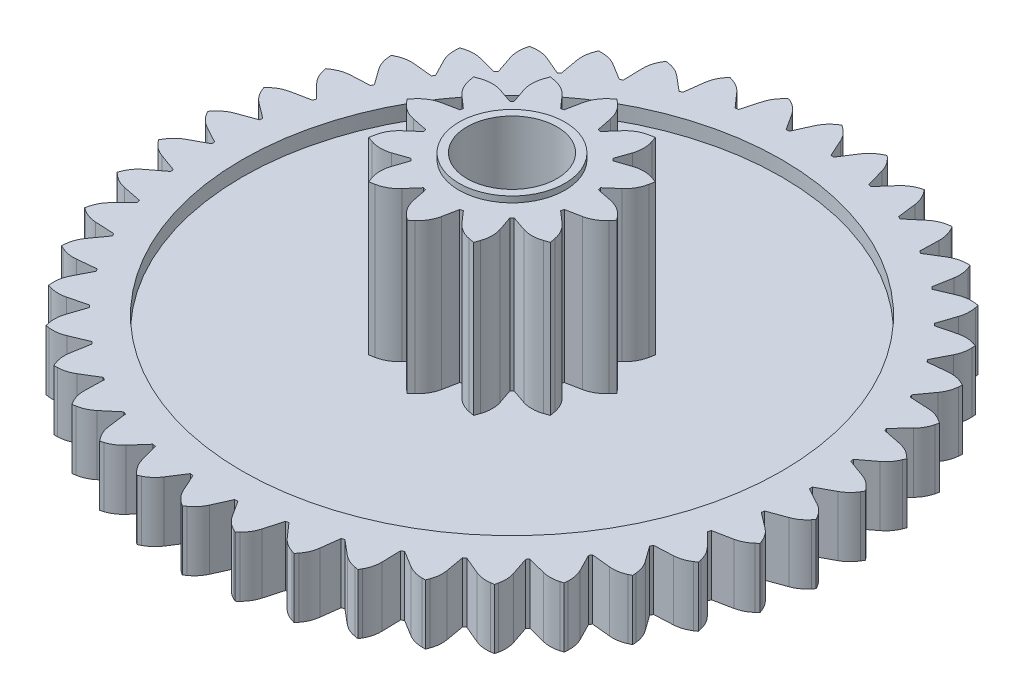
from build123d import *

# Parameters (mm, degrees)
SKETCH1_R           = 11
BOSS_EXTRUDE1_DEPTH = 2
SKETCH2_OUTSIDE_W   = 30.236
SKETCH2_OUTSIDE_H   = 30.236
CUT_EXTRUDE1_DEPTH  = 2
SKETCH3_R           = 9
CUT_EXTRUDE2_DEPTH  = 0.5
SKETCH4_R           = 9
SKETCH4_R_2         = 6.5
SKETCH4_R_3         = 6
CUT_EXTRUDE3_DEPTH  = 0.5
FILLET1_R           = 0.2
BOSS_EXTRUDE2_DEPTH = 5
SKETCH6_R           = 1.5
CUT_EXTRUDE4_DEPTH  = 7.5
SKETCH7_R           = 1.769136677
SKETCH7_R_2         = 1.5
BOSS_EXTRUDE3_DEPTH = 0.2


with BuildPart() as part:
    # Sketch1 → Boss-Extrude1 (new body)
    with BuildSketch(Plane(origin=(0, 0, 0), x_dir=(1, 0, 0), z_dir=(0, 1, 0))):
        Circle(SKETCH1_R)
    extrude(amount=BOSS_EXTRUDE1_DEPTH)

    # Sketch2 outside → Cut-Extrude1 (cut)
    with BuildSketch(Plane(origin=(0, 2, 0), x_dir=(1, 0, 0), z_dir=(0, 1, 0))):
        Rectangle(SKETCH2_OUTSIDE_W, SKETCH2_OUTSIDE_H)
        with BuildLine():
            Line((0.79486256, 9.937629242), (0.695142181, 9.945102252))
            Line((0.695142181, 9.945102252), (0.434286573, 10.524405322))
            ThreePointArc((0.434286573, 10.524405322), (0.292252152, 10.752119541), (0.094771839, 10.933858552))
            Line((0.094771839, 10.933858552), (0, 11))
            Line((0, 11), (-0.094771839, 10.933858552))
            ThreePointArc((-0.094771839, 10.933858552), (-0.292252152, 10.752119541), (-0.434286573, 10.524405322))
            Line((-0.434286573, 10.524405322), (-0.695142181, 9.945102252))
            Line((-0.695142181, 9.945102252), (-0.79486256, 9.937629242))
            Line((-0.79486256, 9.937629242), (-1.139145269, 10.471583465))
            ThreePointArc((-1.139145269, 10.471583465), (-1.313532325, 10.675585173), (-1.535893741, 10.825861396))
            Line((-1.535893741, 10.825861396), (-1.639464928, 10.877139088))
            Line((-1.639464928, 10.877139088), (-1.723320373, 10.797611376))
            ThreePointArc((-1.723320373, 10.797611376), (-1.8915082, 10.588469327), (-1.99801717, 10.342129355))
            Line((-1.99801717, 10.342129355), (-2.169618594, 9.730418111))
            Line((-2.169618594, 9.730418111), (-2.267111385, 9.708166017))
            Line((-2.267111385, 9.708166017), (-2.687130487, 10.184843737))
            ThreePointArc((-2.687130487, 10.184843737), (-2.889974661, 10.360575872), (-3.132249992, 10.476032385))
            Line((-3.132249992, 10.476032385), (-3.242306919, 10.511300864))
            Line((-3.242306919, 10.511300864), (-3.313372777, 10.420163405))
            ThreePointArc((-3.313372777, 10.420163405), (-3.44851108, 10.188290204), (-3.517115365, 9.928827308))
            Line((-3.517115365, 9.928827308), (-3.595629313, 9.298372508))
            Line((-3.595629313, 9.298372508), (-3.688716687, 9.261838405))
            Line((-3.688716687, 9.261838405), (-4.175089651, 9.67059143))
            ThreePointArc((-4.175089651, 9.67059143), (-4.401859739, 9.814128427), (-4.658636955, 9.892186122))
            Line((-4.658636955, 9.892186122), (-4.77272113, 9.910657547))
            Line((-4.77272113, 9.910657547), (-4.829409908, 9.809946202))
            ThreePointArc((-4.829409908, 9.809946202), (-4.928479921, 9.560521514), (-4.957647015, 9.293731666))
            Line((-4.957647015, 9.293731666), (-4.941319614, 8.658616628))
            Line((-4.941319614, 8.658616628), (-5.027922155, 8.608616628))
            Line((-5.027922155, 8.608616628), (-5.569784211, 8.940314091))
            ThreePointArc((-5.569784211, 8.940314091), (-5.815414544, 9.048449571), (-6.080957666, 9.087364767))
            Line((-6.080957666, 9.087364767), (-6.196520639, 9.088626517))
            Line((-6.196520639, 9.088626517), (-6.237566003, 8.980591011))
            ThreePointArc((-6.237566003, 8.980591011), (-6.298354665, 8.719186572), (-6.287433023, 8.451029416))
            Line((-6.287433023, 8.451029416), (-6.176629001, 7.825441561))
            Line((-6.176629001, 7.825441561), (-6.254812149, 7.763092581))
            Line((-6.254812149, 7.763092581), (-6.840058996, 8.010324908))
            ThreePointArc((-6.840058996, 8.010324908), (-7.099062598, 8.080643303), (-7.367439832, 8.079546699))
            Line((-7.367439832, 8.079546699), (-7.481900115, 8.06357059))
            Line((-7.481900115, 8.06357059), (-7.50638518, 7.950624257))
            ThreePointArc((-7.50638518, 7.950624257), (-7.527534573, 7.683079409), (-7.476768166, 7.419545134))
            Line((-7.476768166, 7.419545134), (-7.273962703, 6.817459061))
            Line((-7.273962703, 6.817459061), (-7.341979976, 6.744153874))
            Line((-7.341979976, 6.744153874), (-7.957538166, 6.901398304))
            ThreePointArc((-7.957538166, 6.901398304), (-8.224129324, 6.932328816), (-8.489345566, 6.89124491))
            Line((-8.489345566, 6.89124491), (-8.600146307, 6.85838782))
            Line((-8.600146307, 6.85838782), (-8.607524116, 6.743053695))
            ThreePointArc((-8.607524116, 6.743053695), (-8.588561797, 6.475344949), (-8.499084664, 6.222320474))
            Line((-8.499084664, 6.222320474), (-8.208808097, 5.657185791))
            Line((-8.208808097, 5.657185791), (-8.265140103, 5.574561913))
            Line((-8.265140103, 5.574561913), (-8.897259082, 5.638305865))
            ThreePointArc((-8.897259082, 5.638305865), (-9.165482591, 5.629157559), (-9.421613348, 5.549004096))
            Line((-9.421613348, 5.549004096), (-9.526279442, 5.5))
            Line((-9.526279442, 5.5), (-9.516385187, 5.384854456))
            ThreePointArc((-9.516385187, 5.384854456), (-9.457734743, 5.122961982), (-9.331545655, 4.886099456))
            Line((-9.331545655, 4.886099456), (-8.960282283, 4.370540338))
            Line((-8.960282283, 4.370540338), (-9.003670657, 4.280443452))
            Line((-9.003670657, 4.280443452), (-9.638229933, 4.249262991))
            ThreePointArc((-9.638229933, 4.249262991), (-9.902094122, 4.200240224), (-10.143417857, 4.082807701))
            Line((-10.143417857, 4.082807701), (-10.239611235, 4.018751268))
            Line((-10.239611235, 4.018751268), (-10.212665938, 3.906366467))
            ThreePointArc((-10.212665938, 3.906366467), (-10.115637524, 3.656140511), (-9.955555336, 3.440731051))
            Line((-9.955555336, 3.440731051), (-9.51159857, 2.986264237))
            Line((-9.51159857, 2.986264237), (-9.541074087, 2.890706956))
            Line((-9.541074087, 2.890706956), (-10.163898654, 2.765298603))
            ThreePointArc((-10.163898654, 2.765298603), (-10.417509234, 2.677496463), (-10.638635172, 2.525408128))
            Line((-10.638635172, 2.525408128), (-10.724207034, 2.447730274))
            Line((-10.724207034, 2.447730274), (-10.680812609, 2.340616705))
            ThreePointArc((-10.680812609, 2.340616705), (-10.547573678, 2.107646901), (-10.357174361, 1.9185024))
            Line((-10.357174361, 1.9185024), (-9.850441462, 1.535279927))
            Line((-9.850441462, 1.535279927), (-9.865345689, 1.436396844))
            Line((-9.865345689, 1.436396844), (-10.462522674, 1.219562014))
            ThreePointArc((-10.462522674, 1.219562014), (-10.700214404, 1.094941856), (-10.896202958, 0.911595111))
            Line((-10.896202958, 0.911595111), (-10.969241769, 0.822031029))
            Line((-10.969241769, 0.822031029), (-10.910367575, 0.722581435))
            ThreePointArc((-10.910367575, 0.722581435), (-10.743894465, 0.512071943), (-10.527431226, 0.353417575))
            Line((-10.527431226, 0.353417575), (-9.969241769, 0.05))
            Line((-9.969241769, 0.05), (-9.969241769, -0.05))
            Line((-9.969241769, -0.05), (-10.527431226, -0.353417575))
            ThreePointArc((-10.527431226, -0.353417575), (-10.743894465, -0.512071943), (-10.910367575, -0.722581435))
            Line((-10.910367575, -0.722581435), (-10.969241769, -0.822031029))
            Line((-10.969241769, -0.822031029), (-10.896202958, -0.911595111))
            ThreePointArc((-10.896202958, -0.911595111), (-10.700214404, -1.094941856), (-10.462522674, -1.219562014))
            Line((-10.462522674, -1.219562014), (-9.865345689, -1.436396844))
            Line((-9.865345689, -1.436396844), (-9.850441462, -1.535279927))
            Line((-9.850441462, -1.535279927), (-10.357174361, -1.9185024))
            ThreePointArc((-10.357174361, -1.9185024), (-10.547573678, -2.107646901), (-10.680812609, -2.340616705))
            Line((-10.680812609, -2.340616705), (-10.724207034, -2.447730274))
            Line((-10.724207034, -2.447730274), (-10.638635172, -2.525408128))
            ThreePointArc((-10.638635172, -2.525408128), (-10.417509234, -2.677496463), (-10.163898654, -2.765298603))
            Line((-10.163898654, -2.765298603), (-9.541074087, -2.890706956))
            Line((-9.541074087, -2.890706956), (-9.51159857, -2.986264237))
            Line((-9.51159857, -2.986264237), (-9.955555336, -3.440731051))
            ThreePointArc((-9.955555336, -3.440731051), (-10.115637524, -3.656140511), (-10.212665938, -3.906366467))
            Line((-10.212665938, -3.906366467), (-10.239611235, -4.018751268))
            Line((-10.239611235, -4.018751268), (-10.143417857, -4.082807701))
            ThreePointArc((-10.143417857, -4.082807701), (-9.902094122, -4.200240224), (-9.638229933, -4.249262991))
            Line((-9.638229933, -4.249262991), (-9.003670657, -4.280443452))
            Line((-9.003670657, -4.280443452), (-8.960282283, -4.370540338))
            Line((-8.960282283, -4.370540338), (-9.331545655, -4.886099456))
            ThreePointArc((-9.331545655, -4.886099456), (-9.457734743, -5.122961982), (-9.516385187, -5.384854456))
            Line((-9.516385187, -5.384854456), (-9.526279442, -5.5))
            Line((-9.526279442, -5.5), (-9.421613348, -5.549004096))
            ThreePointArc((-9.421613348, -5.549004096), (-9.165482591, -5.629157559), (-8.897259082, -5.638305865))
            Line((-8.897259082, -5.638305865), (-8.265140103, -5.574561913))
            Line((-8.265140103, -5.574561913), (-8.208808097, -5.657185791))
            Line((-8.208808097, -5.657185791), (-8.499084664, -6.222320474))
            ThreePointArc((-8.499084664, -6.222320474), (-8.588561797, -6.475344949), (-8.607524116, -6.743053695))
            Line((-8.607524116, -6.743053695), (-8.600146307, -6.85838782))
            Line((-8.600146307, -6.85838782), (-8.489345566, -6.89124491))
            ThreePointArc((-8.489345566, -6.89124491), (-8.224129324, -6.932328816), (-7.957538166, -6.901398304))
            Line((-7.957538166, -6.901398304), (-7.341979976, -6.744153874))
            Line((-7.341979976, -6.744153874), (-7.273962703, -6.817459061))
            Line((-7.273962703, -6.817459061), (-7.476768166, -7.419545134))
            ThreePointArc((-7.476768166, -7.419545134), (-7.527534573, -7.683079409), (-7.50638518, -7.950624257))
            Line((-7.50638518, -7.950624257), (-7.481900115, -8.06357059))
            Line((-7.481900115, -8.06357059), (-7.367439832, -8.079546699))
            ThreePointArc((-7.367439832, -8.079546699), (-7.099062598, -8.080643303), (-6.840058996, -8.010324908))
            Line((-6.840058996, -8.010324908), (-6.254812149, -7.763092581))
            Line((-6.254812149, -7.763092581), (-6.176629001, -7.825441561))
            Line((-6.176629001, -7.825441561), (-6.287433023, -8.451029416))
            ThreePointArc((-6.287433023, -8.451029416), (-6.298354665, -8.719186572), (-6.237566003, -8.980591011))
            Line((-6.237566003, -8.980591011), (-6.196520639, -9.088626517))
            Line((-6.196520639, -9.088626517), (-6.080957666, -9.087364767))
            ThreePointArc((-6.080957666, -9.087364767), (-5.815414544, -9.048449571), (-5.569784211, -8.940314091))
            Line((-5.569784211, -8.940314091), (-5.027922155, -8.608616628))
            Line((-5.027922155, -8.608616628), (-4.941319614, -8.658616628))
            Line((-4.941319614, -8.658616628), (-4.957647015, -9.293731666))
            ThreePointArc((-4.957647015, -9.293731666), (-4.928479921, -9.560521514), (-4.829409908, -9.809946202))
            Line((-4.829409908, -9.809946202), (-4.77272113, -9.910657547))
            Line((-4.77272113, -9.910657547), (-4.658636955, -9.892186122))
            ThreePointArc((-4.658636955, -9.892186122), (-4.401859739, -9.814128427), (-4.175089651, -9.67059143))
            Line((-4.175089651, -9.67059143), (-3.688716687, -9.261838405))
            Line((-3.688716687, -9.261838405), (-3.595629313, -9.298372508))
            Line((-3.595629313, -9.298372508), (-3.517115365, -9.928827308))
            ThreePointArc((-3.517115365, -9.928827308), (-3.44851108, -10.188290204), (-3.313372777, -10.420163405))
            Line((-3.313372777, -10.420163405), (-3.242306919, -10.511300864))
            Line((-3.242306919, -10.511300864), (-3.132249992, -10.476032385))
            ThreePointArc((-3.132249992, -10.476032385), (-2.889974661, -10.360575872), (-2.687130487, -10.184843737))
            Line((-2.687130487, -10.184843737), (-2.267111385, -9.708166017))
            Line((-2.267111385, -9.708166017), (-2.169618594, -9.730418111))
            Line((-2.169618594, -9.730418111), (-1.99801717, -10.342129355))
            ThreePointArc((-1.99801717, -10.342129355), (-1.8915082, -10.588469327), (-1.723320373, -10.797611376))
            Line((-1.723320373, -10.797611376), (-1.639464928, -10.877139088))
            Line((-1.639464928, -10.877139088), (-1.535893741, -10.825861396))
            ThreePointArc((-1.535893741, -10.825861396), (-1.313532325, -10.675585173), (-1.139145269, -10.471583465))
            Line((-1.139145269, -10.471583465), (-0.79486256, -9.937629242))
            Line((-0.79486256, -9.937629242), (-0.695142181, -9.945102252))
            Line((-0.695142181, -9.945102252), (-0.434286573, -10.524405322))
            ThreePointArc((-0.434286573, -10.524405322), (-0.292252152, -10.752119541), (-0.094771839, -10.933858552))
            Line((-0.094771839, -10.933858552), (0, -11))
            Line((0, -11), (0.094771839, -10.933858552))
            ThreePointArc((0.094771839, -10.933858552), (0.292252152, -10.752119541), (0.434286573, -10.524405322))
            Line((0.434286573, -10.524405322), (0.695142181, -9.945102252))
            Line((0.695142181, -9.945102252), (0.79486256, -9.937629242))
            Line((0.79486256, -9.937629242), (1.139145269, -10.471583465))
            ThreePointArc((1.139145269, -10.471583465), (1.313532325, -10.675585173), (1.535893741, -10.825861396))
            Line((1.535893741, -10.825861396), (1.639464928, -10.877139088))
            Line((1.639464928, -10.877139088), (1.723320373, -10.797611376))
            ThreePointArc((1.723320373, -10.797611376), (1.8915082, -10.588469327), (1.99801717, -10.342129355))
            Line((1.99801717, -10.342129355), (2.169618594, -9.730418111))
            Line((2.169618594, -9.730418111), (2.267111385, -9.708166017))
            Line((2.267111385, -9.708166017), (2.687130487, -10.184843737))
            ThreePointArc((2.687130487, -10.184843737), (2.889974661, -10.360575872), (3.132249992, -10.476032385))
            Line((3.132249992, -10.476032385), (3.242306919, -10.511300864))
            Line((3.242306919, -10.511300864), (3.313372777, -10.420163405))
            ThreePointArc((3.313372777, -10.420163405), (3.44851108, -10.188290204), (3.517115365, -9.928827308))
            Line((3.517115365, -9.928827308), (3.595629313, -9.298372508))
            Line((3.595629313, -9.298372508), (3.688716687, -9.261838405))
            Line((3.688716687, -9.261838405), (4.175089651, -9.67059143))
            ThreePointArc((4.175089651, -9.67059143), (4.401859739, -9.814128427), (4.658636955, -9.892186122))
            Line((4.658636955, -9.892186122), (4.77272113, -9.910657547))
            Line((4.77272113, -9.910657547), (4.829409908, -9.809946202))
            ThreePointArc((4.829409908, -9.809946202), (4.928479921, -9.560521514), (4.957647015, -9.293731666))
            Line((4.957647015, -9.293731666), (4.941319614, -8.658616628))
            Line((4.941319614, -8.658616628), (5.027922155, -8.608616628))
            Line((5.027922155, -8.608616628), (5.569784211, -8.940314091))
            ThreePointArc((5.569784211, -8.940314091), (5.815414544, -9.048449571), (6.080957666, -9.087364767))
            Line((6.080957666, -9.087364767), (6.196520639, -9.088626517))
            Line((6.196520639, -9.088626517), (6.237566003, -8.980591011))
            ThreePointArc((6.237566003, -8.980591011), (6.298354665, -8.719186572), (6.287433023, -8.451029416))
            Line((6.287433023, -8.451029416), (6.176629001, -7.825441561))
            Line((6.176629001, -7.825441561), (6.254812149, -7.763092581))
            Line((6.254812149, -7.763092581), (6.840058996, -8.010324908))
            ThreePointArc((6.840058996, -8.010324908), (7.099062598, -8.080643303), (7.367439832, -8.079546699))
            Line((7.367439832, -8.079546699), (7.481900115, -8.06357059))
            Line((7.481900115, -8.06357059), (7.50638518, -7.950624257))
            ThreePointArc((7.50638518, -7.950624257), (7.527534573, -7.683079409), (7.476768166, -7.419545134))
            Line((7.476768166, -7.419545134), (7.273962703, -6.817459061))
            Line((7.273962703, -6.817459061), (7.341979976, -6.744153874))
            Line((7.341979976, -6.744153874), (7.957538166, -6.901398304))
            ThreePointArc((7.957538166, -6.901398304), (8.224129324, -6.932328816), (8.489345566, -6.89124491))
            Line((8.489345566, -6.89124491), (8.600146307, -6.85838782))
            Line((8.600146307, -6.85838782), (8.607524116, -6.743053695))
            ThreePointArc((8.607524116, -6.743053695), (8.588561797, -6.475344949), (8.499084664, -6.222320474))
            Line((8.499084664, -6.222320474), (8.208808097, -5.657185791))
            Line((8.208808097, -5.657185791), (8.265140103, -5.574561913))
            Line((8.265140103, -5.574561913), (8.897259082, -5.638305865))
            ThreePointArc((8.897259082, -5.638305865), (9.165482591, -5.629157559), (9.421613348, -5.549004096))
            Line((9.421613348, -5.549004096), (9.526279442, -5.5))
            Line((9.526279442, -5.5), (9.516385187, -5.384854456))
            ThreePointArc((9.516385187, -5.384854456), (9.457734743, -5.122961982), (9.331545655, -4.886099456))
            Line((9.331545655, -4.886099456), (8.960282283, -4.370540338))
            Line((8.960282283, -4.370540338), (9.003670657, -4.280443452))
            Line((9.003670657, -4.280443452), (9.638229933, -4.249262991))
            ThreePointArc((9.638229933, -4.249262991), (9.902094122, -4.200240224), (10.143417857, -4.082807701))
            Line((10.143417857, -4.082807701), (10.239611235, -4.018751268))
            Line((10.239611235, -4.018751268), (10.212665938, -3.906366467))
            ThreePointArc((10.212665938, -3.906366467), (10.115637524, -3.656140511), (9.955555336, -3.440731051))
            Line((9.955555336, -3.440731051), (9.51159857, -2.986264237))
            Line((9.51159857, -2.986264237), (9.541074087, -2.890706956))
            Line((9.541074087, -2.890706956), (10.163898654, -2.765298603))
            ThreePointArc((10.163898654, -2.765298603), (10.417509234, -2.677496463), (10.638635172, -2.525408128))
            Line((10.638635172, -2.525408128), (10.724207034, -2.447730274))
            Line((10.724207034, -2.447730274), (10.680812609, -2.340616705))
            ThreePointArc((10.680812609, -2.340616705), (10.547573678, -2.107646901), (10.357174361, -1.9185024))
            Line((10.357174361, -1.9185024), (9.850441462, -1.535279927))
            Line((9.850441462, -1.535279927), (9.865345689, -1.436396844))
            Line((9.865345689, -1.436396844), (10.462522674, -1.219562014))
            ThreePointArc((10.462522674, -1.219562014), (10.700214404, -1.094941856), (10.896202958, -0.911595111))
            Line((10.896202958, -0.911595111), (10.969241769, -0.822031029))
            Line((10.969241769, -0.822031029), (10.910367575, -0.722581435))
            ThreePointArc((10.910367575, -0.722581435), (10.743894465, -0.512071943), (10.527431226, -0.353417575))
            Line((10.527431226, -0.353417575), (9.969241769, -0.05))
            Line((9.969241769, -0.05), (9.969241769, 0.05))
            Line((9.969241769, 0.05), (10.527431226, 0.353417575))
            ThreePointArc((10.527431226, 0.353417575), (10.743894465, 0.512071943), (10.910367575, 0.722581435))
            Line((10.910367575, 0.722581435), (10.969241769, 0.822031029))
            Line((10.969241769, 0.822031029), (10.896202958, 0.911595111))
            ThreePointArc((10.896202958, 0.911595111), (10.700214404, 1.094941856), (10.462522674, 1.219562014))
            Line((10.462522674, 1.219562014), (9.865345689, 1.436396844))
            Line((9.865345689, 1.436396844), (9.850441462, 1.535279927))
            Line((9.850441462, 1.535279927), (10.357174361, 1.9185024))
            ThreePointArc((10.357174361, 1.9185024), (10.547573678, 2.107646901), (10.680812609, 2.340616705))
            Line((10.680812609, 2.340616705), (10.724207034, 2.447730274))
            Line((10.724207034, 2.447730274), (10.638635172, 2.525408128))
            ThreePointArc((10.638635172, 2.525408128), (10.417509234, 2.677496463), (10.163898654, 2.765298603))
            Line((10.163898654, 2.765298603), (9.541074087, 2.890706956))
            Line((9.541074087, 2.890706956), (9.51159857, 2.986264237))
            Line((9.51159857, 2.986264237), (9.955555336, 3.440731051))
            ThreePointArc((9.955555336, 3.440731051), (10.115637524, 3.656140511), (10.212665938, 3.906366467))
            Line((10.212665938, 3.906366467), (10.239611235, 4.018751268))
            Line((10.239611235, 4.018751268), (10.143417857, 4.082807701))
            ThreePointArc((10.143417857, 4.082807701), (9.902094122, 4.200240224), (9.638229933, 4.249262991))
            Line((9.638229933, 4.249262991), (9.003670657, 4.280443452))
            Line((9.003670657, 4.280443452), (8.960282283, 4.370540338))
            Line((8.960282283, 4.370540338), (9.331545655, 4.886099456))
            ThreePointArc((9.331545655, 4.886099456), (9.457734743, 5.122961982), (9.516385187, 5.384854456))
            Line((9.516385187, 5.384854456), (9.526279442, 5.5))
            Line((9.526279442, 5.5), (9.421613348, 5.549004096))
            ThreePointArc((9.421613348, 5.549004096), (9.165482591, 5.629157559), (8.897259082, 5.638305865))
            Line((8.897259082, 5.638305865), (8.265140103, 5.574561913))
            Line((8.265140103, 5.574561913), (8.208808097, 5.657185791))
            Line((8.208808097, 5.657185791), (8.499084664, 6.222320474))
            ThreePointArc((8.499084664, 6.222320474), (8.588561797, 6.475344949), (8.607524116, 6.743053695))
            Line((8.607524116, 6.743053695), (8.600146307, 6.85838782))
            Line((8.600146307, 6.85838782), (8.489345566, 6.89124491))
            ThreePointArc((8.489345566, 6.89124491), (8.224129324, 6.932328816), (7.957538166, 6.901398304))
            Line((7.957538166, 6.901398304), (7.341979976, 6.744153874))
            Line((7.341979976, 6.744153874), (7.273962703, 6.817459061))
            Line((7.273962703, 6.817459061), (7.476768166, 7.419545134))
            ThreePointArc((7.476768166, 7.419545134), (7.527534573, 7.683079409), (7.50638518, 7.950624257))
            Line((7.50638518, 7.950624257), (7.481900115, 8.06357059))
            Line((7.481900115, 8.06357059), (7.367439832, 8.079546699))
            ThreePointArc((7.367439832, 8.079546699), (7.099062598, 8.080643303), (6.840058996, 8.010324908))
            Line((6.840058996, 8.010324908), (6.254812149, 7.763092581))
            Line((6.254812149, 7.763092581), (6.176629001, 7.825441561))
            Line((6.176629001, 7.825441561), (6.287433023, 8.451029416))
            ThreePointArc((6.287433023, 8.451029416), (6.298354665, 8.719186572), (6.237566003, 8.980591011))
            Line((6.237566003, 8.980591011), (6.196520639, 9.088626517))
            Line((6.196520639, 9.088626517), (6.080957666, 9.087364767))
            ThreePointArc((6.080957666, 9.087364767), (5.815414544, 9.048449571), (5.569784211, 8.940314091))
            Line((5.569784211, 8.940314091), (5.027922155, 8.608616628))
            Line((5.027922155, 8.608616628), (4.941319614, 8.658616628))
            Line((4.941319614, 8.658616628), (4.957647015, 9.293731666))
            ThreePointArc((4.957647015, 9.293731666), (4.928479921, 9.560521514), (4.829409908, 9.809946202))
            Line((4.829409908, 9.809946202), (4.77272113, 9.910657547))
            Line((4.77272113, 9.910657547), (4.658636955, 9.892186122))
            ThreePointArc((4.658636955, 9.892186122), (4.401859739, 9.814128427), (4.175089651, 9.67059143))
            Line((4.175089651, 9.67059143), (3.688716687, 9.261838405))
            Line((3.688716687, 9.261838405), (3.595629313, 9.298372508))
            Line((3.595629313, 9.298372508), (3.517115365, 9.928827308))
            ThreePointArc((3.517115365, 9.928827308), (3.44851108, 10.188290204), (3.313372777, 10.420163405))
            Line((3.313372777, 10.420163405), (3.242306919, 10.511300864))
            Line((3.242306919, 10.511300864), (3.132249992, 10.476032385))
            ThreePointArc((3.132249992, 10.476032385), (2.889974661, 10.360575872), (2.687130487, 10.184843737))
            Line((2.687130487, 10.184843737), (2.267111385, 9.708166017))
            Line((2.267111385, 9.708166017), (2.169618594, 9.730418111))
            Line((2.169618594, 9.730418111), (1.99801717, 10.342129355))
            ThreePointArc((1.99801717, 10.342129355), (1.8915082, 10.588469327), (1.723320373, 10.797611376))
            Line((1.723320373, 10.797611376), (1.639464928, 10.877139088))
            Line((1.639464928, 10.877139088), (1.535893741, 10.825861396))
            ThreePointArc((1.535893741, 10.825861396), (1.313532325, 10.675585173), (1.139145269, 10.471583465))
            Line((1.139145269, 10.471583465), (0.79486256, 9.937629242))
        make_face(mode=Mode.SUBTRACT)
    extrude(amount=-CUT_EXTRUDE1_DEPTH, mode=Mode.SUBTRACT)

    # Sketch3 → Cut-Extrude2 (cut)
    with BuildSketch(Plane(origin=(0, 2, 0), x_dir=(1, 0, 0), z_dir=(0, 1, 0))):
        Circle(SKETCH3_R)
    extrude(amount=-CUT_EXTRUDE2_DEPTH, mode=Mode.SUBTRACT)

    # Sketch4 → Cut-Extrude3 (cut)
    with BuildSketch(Plane.XZ):
        Circle(SKETCH4_R)
        Circle(SKETCH4_R_2, mode=Mode.SUBTRACT)
        Circle(SKETCH4_R_3)
    extrude(amount=-CUT_EXTRUDE3_DEPTH, mode=Mode.SUBTRACT)

    # Fillet1
    fillet1_edges = [part.edges().sort_by_distance(p)[0] for p in [
        (-6.5, 0, 0),
        (-6, 0, 0),
    ]]
    fillet(fillet1_edges, radius=FILLET1_R)

    # Sketch5 → Boss-Extrude2 (add)
    with BuildSketch(Plane(origin=(0, 1.5, 0), x_dir=(1, 0, 0), z_dir=(0, 1, 0))):
        with BuildLine():
            Line((0.664477246, 2.286677678), (0.567884664, 2.312559583))
            Line((0.567884664, 2.312559583), (0.467800716, 2.816836716))
            ThreePointArc((0.467800716, 2.816836716), (0.350776507, 3.125923121), (0.139395422, 3.37998435))
            Line((0.139395422, 3.37998435), (0, 3.5))
            Line((0, 3.5), (-0.139395422, 3.37998435))
            ThreePointArc((-0.139395422, 3.37998435), (-0.350776507, 3.125923121), (-0.467800716, 2.816836716))
            Line((-0.467800716, 2.816836716), (-0.567884664, 2.312559583))
            Line((-0.567884664, 2.312559583), (-0.664477246, 2.286677678))
            Line((-0.664477246, 2.286677678), (-1.003291054, 2.673352512))
            ThreePointArc((-1.003291054, 2.673352512), (-1.259180194, 2.882517086), (-1.569272199, 2.996850022))
            Line((-1.569272199, 2.996850022), (-1.75, 3.031088913))
            Line((-1.75, 3.031088913), (-1.810712151, 2.8574546))
            ThreePointArc((-1.810712151, 2.8574546), (-1.866742926, 2.531740579), (-1.813545662, 2.205551796))
            Line((-1.813545662, 2.205551796), (-1.648082336, 1.718793014))
            Line((-1.648082336, 1.718793014), (-1.718793014, 1.648082336))
            Line((-1.718793014, 1.648082336), (-2.205551796, 1.813545662))
            ThreePointArc((-2.205551796, 1.813545662), (-2.531740579, 1.866742926), (-2.8574546, 1.810712151))
            Line((-2.8574546, 1.810712151), (-3.031088913, 1.75))
            Line((-3.031088913, 1.75), (-2.996850022, 1.569272199))
            ThreePointArc((-2.996850022, 1.569272199), (-2.882517086, 1.259180194), (-2.673352512, 1.003291054))
            Line((-2.673352512, 1.003291054), (-2.286677678, 0.664477246))
            Line((-2.286677678, 0.664477246), (-2.312559583, 0.567884664))
            Line((-2.312559583, 0.567884664), (-2.816836716, 0.467800716))
            ThreePointArc((-2.816836716, 0.467800716), (-3.125923121, 0.350776507), (-3.37998435, 0.139395422))
            Line((-3.37998435, 0.139395422), (-3.5, 0))
            Line((-3.5, 0), (-3.37998435, -0.139395422))
            ThreePointArc((-3.37998435, -0.139395422), (-3.125923121, -0.350776507), (-2.816836716, -0.467800716))
            Line((-2.816836716, -0.467800716), (-2.312559583, -0.567884664))
            Line((-2.312559583, -0.567884664), (-2.286677678, -0.664477246))
            Line((-2.286677678, -0.664477246), (-2.673352512, -1.003291054))
            ThreePointArc((-2.673352512, -1.003291054), (-2.882517086, -1.259180194), (-2.996850022, -1.569272199))
            Line((-2.996850022, -1.569272199), (-3.031088913, -1.75))
            Line((-3.031088913, -1.75), (-2.8574546, -1.810712151))
            ThreePointArc((-2.8574546, -1.810712151), (-2.531740579, -1.866742926), (-2.205551796, -1.813545662))
            Line((-2.205551796, -1.813545662), (-1.718793014, -1.648082336))
            Line((-1.718793014, -1.648082336), (-1.648082336, -1.718793014))
            Line((-1.648082336, -1.718793014), (-1.813545662, -2.205551796))
            ThreePointArc((-1.813545662, -2.205551796), (-1.866742926, -2.531740579), (-1.810712151, -2.8574546))
            Line((-1.810712151, -2.8574546), (-1.75, -3.031088913))
            Line((-1.75, -3.031088913), (-1.569272199, -2.996850022))
            ThreePointArc((-1.569272199, -2.996850022), (-1.259180194, -2.882517086), (-1.003291054, -2.673352512))
            Line((-1.003291054, -2.673352512), (-0.664477246, -2.286677678))
            Line((-0.664477246, -2.286677678), (-0.567884664, -2.312559583))
            Line((-0.567884664, -2.312559583), (-0.467800716, -2.816836716))
            ThreePointArc((-0.467800716, -2.816836716), (-0.350776507, -3.125923121), (-0.139395422, -3.37998435))
            Line((-0.139395422, -3.37998435), (0, -3.5))
            Line((0, -3.5), (0.139395422, -3.37998435))
            ThreePointArc((0.139395422, -3.37998435), (0.350776507, -3.125923121), (0.467800716, -2.816836716))
            Line((0.467800716, -2.816836716), (0.567884664, -2.312559583))
            Line((0.567884664, -2.312559583), (0.664477246, -2.286677678))
            Line((0.664477246, -2.286677678), (1.003291054, -2.673352512))
            ThreePointArc((1.003291054, -2.673352512), (1.259180194, -2.882517086), (1.569272199, -2.996850022))
            Line((1.569272199, -2.996850022), (1.75, -3.031088913))
            Line((1.75, -3.031088913), (1.810712151, -2.8574546))
            ThreePointArc((1.810712151, -2.8574546), (1.866742926, -2.531740579), (1.813545662, -2.205551796))
            Line((1.813545662, -2.205551796), (1.648082336, -1.718793014))
            Line((1.648082336, -1.718793014), (1.718793014, -1.648082336))
            Line((1.718793014, -1.648082336), (2.205551796, -1.813545662))
            ThreePointArc((2.205551796, -1.813545662), (2.531740579, -1.866742926), (2.8574546, -1.810712151))
            Line((2.8574546, -1.810712151), (3.031088913, -1.75))
            Line((3.031088913, -1.75), (2.996850022, -1.569272199))
            ThreePointArc((2.996850022, -1.569272199), (2.882517086, -1.259180194), (2.673352512, -1.003291054))
            Line((2.673352512, -1.003291054), (2.286677678, -0.664477246))
            Line((2.286677678, -0.664477246), (2.312559583, -0.567884664))
            Line((2.312559583, -0.567884664), (2.816836716, -0.467800716))
            ThreePointArc((2.816836716, -0.467800716), (3.125923121, -0.350776507), (3.37998435, -0.139395422))
            Line((3.37998435, -0.139395422), (3.5, 0))
            Line((3.5, 0), (3.37998435, 0.139395422))
            ThreePointArc((3.37998435, 0.139395422), (3.125923121, 0.350776507), (2.816836716, 0.467800716))
            Line((2.816836716, 0.467800716), (2.312559583, 0.567884664))
            Line((2.312559583, 0.567884664), (2.286677678, 0.664477246))
            Line((2.286677678, 0.664477246), (2.673352512, 1.003291054))
            ThreePointArc((2.673352512, 1.003291054), (2.882517086, 1.259180194), (2.996850022, 1.569272199))
            Line((2.996850022, 1.569272199), (3.031088913, 1.75))
            Line((3.031088913, 1.75), (2.8574546, 1.810712151))
            ThreePointArc((2.8574546, 1.810712151), (2.531740579, 1.866742926), (2.205551796, 1.813545662))
            Line((2.205551796, 1.813545662), (1.718793014, 1.648082336))
            Line((1.718793014, 1.648082336), (1.648082336, 1.718793014))
            Line((1.648082336, 1.718793014), (1.813545662, 2.205551796))
            ThreePointArc((1.813545662, 2.205551796), (1.866742926, 2.531740579), (1.810712151, 2.8574546))
            Line((1.810712151, 2.8574546), (1.75, 3.031088913))
            Line((1.75, 3.031088913), (1.569272199, 2.996850022))
            ThreePointArc((1.569272199, 2.996850022), (1.259180194, 2.882517086), (1.003291054, 2.673352512))
            Line((1.003291054, 2.673352512), (0.664477246, 2.286677678))
        make_face()
    extrude(amount=BOSS_EXTRUDE2_DEPTH)

    # Sketch6 → Cut-Extrude4 (cut, through all)
    with BuildSketch(Plane(origin=(0, 6.5, 0), x_dir=(1, 0, 0), z_dir=(0, 1, 0))):
        Circle(SKETCH6_R)
    extrude(amount=-CUT_EXTRUDE4_DEPTH, mode=Mode.SUBTRACT)

    # Sketch7 → Boss-Extrude3 (add)
    with BuildSketch(Plane(origin=(0, 6.5, 0), x_dir=(1, 0, 0), z_dir=(0, 1, 0))):
        Circle(SKETCH7_R)
        Circle(SKETCH7_R_2, mode=Mode.SUBTRACT)
    extrude(amount=BOSS_EXTRUDE3_DEPTH)


solid = part.part
